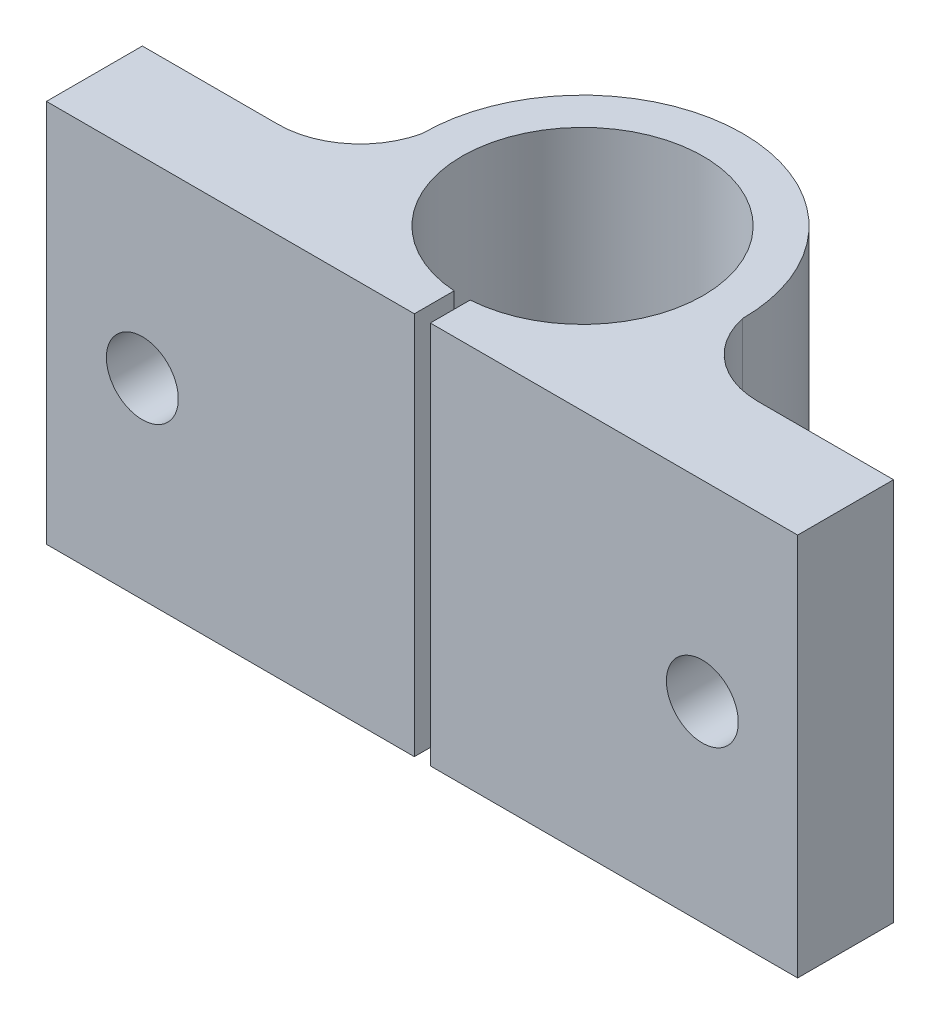
from build123d import *

# Parameters (mm, degrees)
BOSS_EXTRUDE1_DEPTH            = 24
CUT_EXTRUDE1_DEPTH             = 25
SKETCH3_W                      = 7.55
SKETCH3_H                      = 24
F_4_5_4_5_DIAMETER_HOLE1_D     = 4.5
F_4_5_4_5_DIAMETER_HOLE1_DEPTH = 6


with BuildPart() as part:
    # Sketch1 → Boss-Extrude1 (new body)
    with BuildSketch(Plane(origin=(0, 24, 0), x_dir=(1, 0, 0), z_dir=(0, 1, 0))):
        with BuildLine():
            Line((0, 0), (47, 0))
            Line((47, 0), (47, 6))
            Line((47, 6), (38.5, 6))
            ThreePointArc((38.5, 6), (35.307693119, 7.131854655), (33.541354656, 10.021831577))
            ThreePointArc((33.541354656, 10.021831577), (23.505747016, 20.045434485), (13.49594739, 9.996059012))
            ThreePointArc((13.49594739, 9.996059012), (11.698748894, 7.121907302), (8.5, 6))
            Line((8.5, 6), (0, 6))
            Line((0, 6), (0, 0))
        make_face()
    extrude(amount=-BOSS_EXTRUDE1_DEPTH)

    # Sketch2 → Cut-Extrude1 (cut, through all)
    with BuildSketch(Plane.XZ):
        with BuildLine():
            Line((24.018633311, 0), (23.018633311, 0))
            Line((23.018633311, 0), (23.018633311, -2.489295869))
            ThreePointArc((23.018633311, -2.489295869), (23.518633311, -2.472721384), (24.018633311, -2.489295869))
            Line((24.018633311, -2.489295869), (24.018633311, 0))
        make_face()
    extrude(amount=-CUT_EXTRUDE1_DEPTH, mode=Mode.SUBTRACT)

    # Sketch3 → Cut-Revolve1 (revolve, cut)
    with BuildSketch(Plane(origin=(0, 0, -10.022721384), x_dir=(-1, 0, 0), z_dir=(0, 0, -1))):
        with Locations((-27.293633311, 12)):
            Rectangle(SKETCH3_W, SKETCH3_H)
    revolve(axis=Axis((23.518633311, 0, -10.022721384), (0, 1, 0)), mode=Mode.SUBTRACT)

    # Ø4.5 (4.5) Diameter Hole1
    with Locations(Plane(origin=(0, 0, -6), x_dir=(-1, 0, 0), z_dir=(0, 0, -1))):
        with Locations((-41.037266621, 12), (-6, 12)):
            Hole(F_4_5_4_5_DIAMETER_HOLE1_D / 2, depth=F_4_5_4_5_DIAMETER_HOLE1_DEPTH)


solid = part.part
